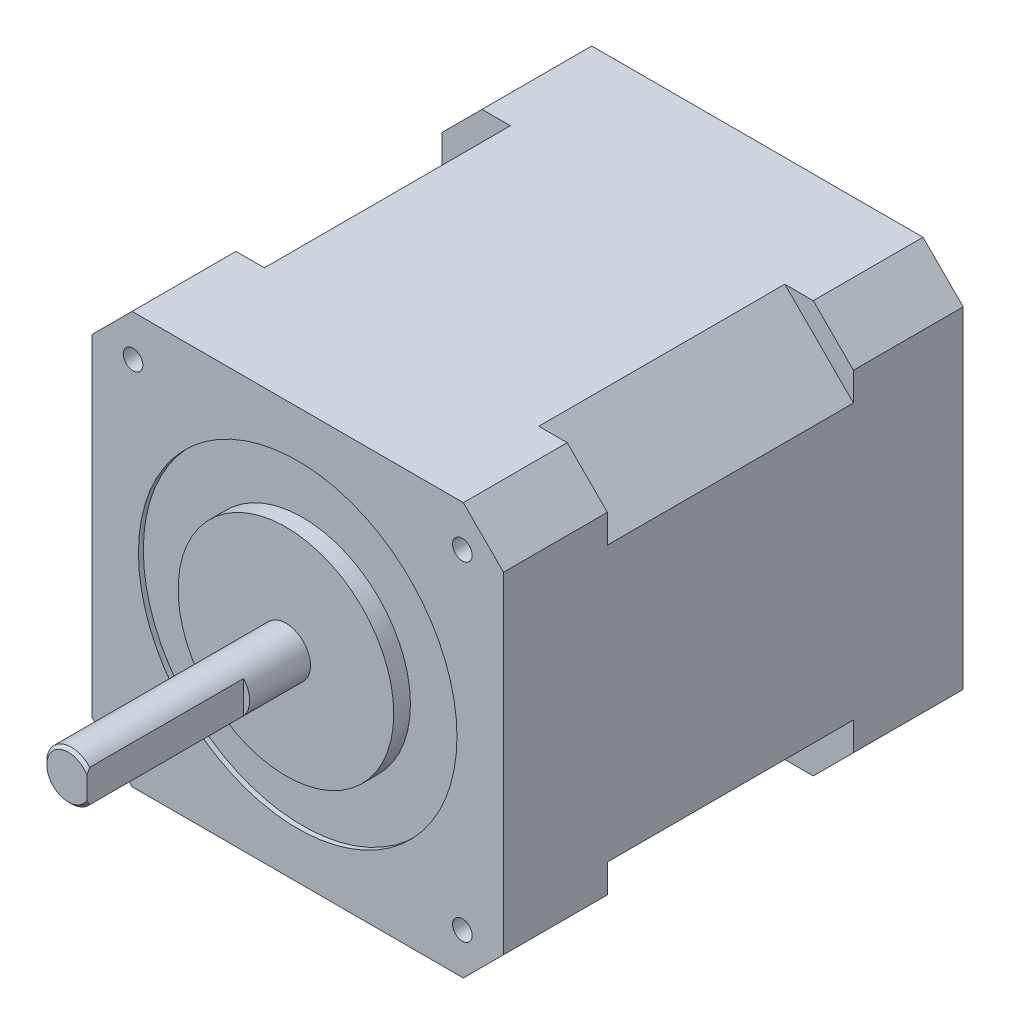
from build123d import *

# Parameters (mm, degrees)
BOSS_EXTRU_1_DEPTH      = 11.2
BOSS_EXTRU_2_DEPTH      = 25.1
BOSS_EXTRU_3_DEPTH      = 10.6
ESQUISSE4_R             = 16.25
ENL_V_MAT_EXTRU_1_DEPTH = 0.5
ESQUISSE5_R             = 11
BOSS_EXTRU_4_DEPTH      = 1.7
ESQUISSE6_R             = 2.5
BOSS_EXTRU_5_DEPTH      = 22.2
CHANFREIN1_SIZE         = 0.3
ENL_V_MAT_EXTRU_2_DEPTH = 16
ESQUISSE8_R             = 1
ENL_V_MAT_EXTRU_3_DEPTH = 10


with BuildPart() as part:
    # Esquisse1 → Boss.-Extru.1 (new body)
    with BuildSketch(Plane.XY):
        Polygon((21, -16.9), (21, 16.9), (16.9, 21), (-16.9, 21), (-21, 16.9), (-21, -16.9), (-16.9, -21), (16.9, -21), align=None)
    extrude(amount=BOSS_EXTRU_1_DEPTH)

    # Esquisse2 → Boss.-Extru.2 (add)
    with BuildSketch(Plane.XY.offset(11.2)):
        Polygon((14, 21), (21, 14), (21, -14), (14, -21), (-14, -21), (-21, -14), (-21, 14), (-14, 21), align=None)
    extrude(amount=BOSS_EXTRU_2_DEPTH)

    # Esquisse3 → Boss.-Extru.3 (add)
    with BuildSketch(Plane.XY.offset(36.3)):
        Polygon((16.9, 21), (21, 16.9), (21, -16.9), (16.9, -21), (-16.9, -21), (-21, -16.9), (-21, 16.9), (-16.9, 21), align=None)
    extrude(amount=BOSS_EXTRU_3_DEPTH)

    # Esquisse4 → Enlèv. mat.-Extru.1 (cut)
    with BuildSketch(Plane.XY.offset(46.9)):
        Circle(ESQUISSE4_R)
    extrude(amount=-ENL_V_MAT_EXTRU_1_DEPTH, mode=Mode.SUBTRACT)

    # Esquisse5 → Boss.-Extru.4 (add)
    with BuildSketch(Plane.XY.offset(46.4)):
        Circle(ESQUISSE5_R)
    extrude(amount=BOSS_EXTRU_4_DEPTH)

    # Esquisse6 → Boss.-Extru.5 (add)
    with BuildSketch(Plane.XY.offset(48.1)):
        Circle(ESQUISSE6_R)
    extrude(amount=BOSS_EXTRU_5_DEPTH)

    # Chanfrein1
    chanfrein1_edges = [part.edges().sort_by_distance(p)[0] for p in [
        (-2.5, 0, 70.3),
    ]]
    chamfer(chanfrein1_edges, length=CHANFREIN1_SIZE)

    # Esquisse7 → Enlèv. mat.-Extru.2 (cut)
    with BuildSketch(Plane.XY.offset(70.3)):
        with BuildLine():
            Line((1.878163997, 1.65), (1.878163997, -1.65))
            ThreePointArc((1.878163997, -1.65), (2.5, 0), (1.878163997, 1.65))
        make_face()
    extrude(amount=-ENL_V_MAT_EXTRU_2_DEPTH, mode=Mode.SUBTRACT)

    # Esquisse8 → Enlèv. mat.-Extru.3 (cut)
    with BuildSketch(Plane.XY.offset(46.9)):
        with Locations((-16.8, 16.8)):
            Circle(ESQUISSE8_R)
        with Locations((-16.8, -16.8)):
            Circle(ESQUISSE8_R)
        with Locations((16.8, -16.8)):
            Circle(ESQUISSE8_R)
        with Locations((16.8, 16.8)):
            Circle(ESQUISSE8_R)
    extrude(amount=-ENL_V_MAT_EXTRU_3_DEPTH, mode=Mode.SUBTRACT)


solid = part.part
